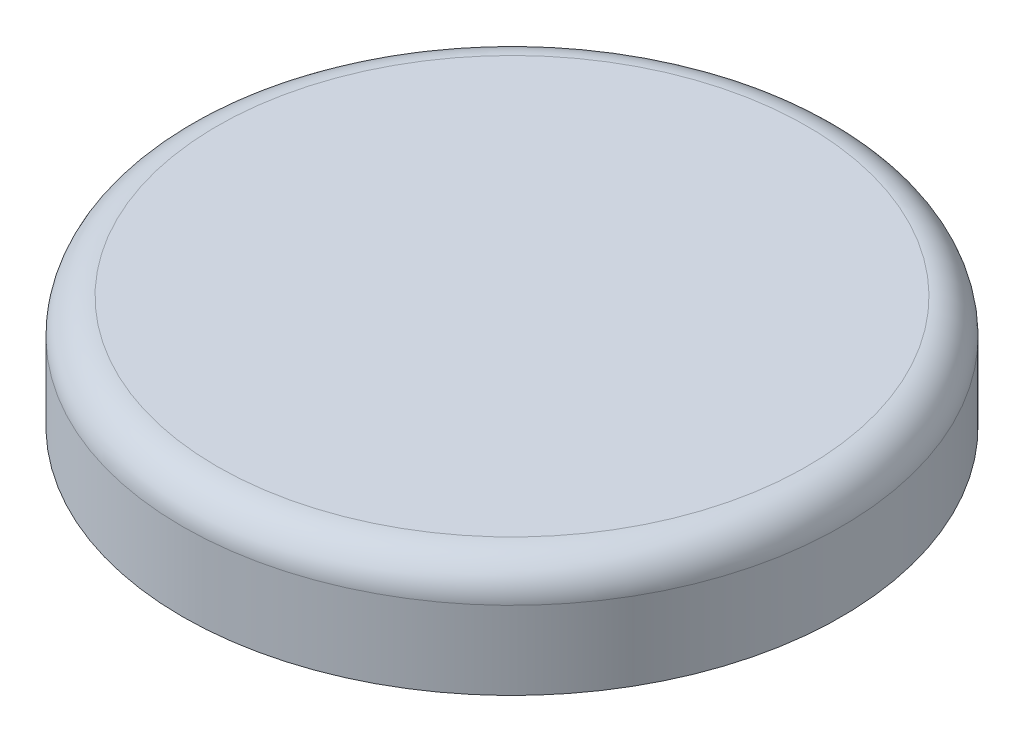
from build123d import *

# Parameters (mm, degrees)
SKETCH1_R           = 7.6
BOSS_EXTRUDE1_DEPTH = 2.6
FILLET1_R           = 0.8


with BuildPart() as part:
    # Sketch1 → Boss-Extrude1 (new body)
    with BuildSketch(Plane(origin=(0, 0, 0), x_dir=(1, 0, 0), z_dir=(0, 1, 0))):
        Circle(SKETCH1_R)
    extrude(amount=BOSS_EXTRUDE1_DEPTH)

    # Fillet1
    fillet1_edges = [part.edges().sort_by_distance(p)[0] for p in [
        (-7.6, 2.6, 0),
    ]]
    fillet(fillet1_edges, radius=FILLET1_R)


solid = part.part
